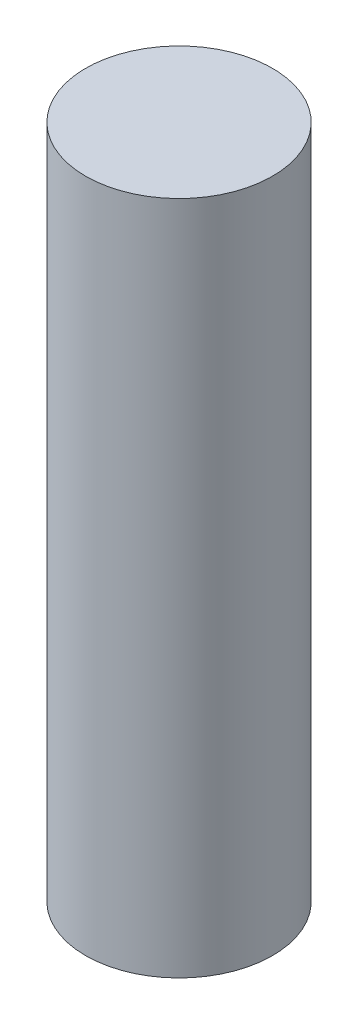
from build123d import *

# Parameters (mm, degrees)
ESQUISSE1_R        = 9
BOSS_EXTRU_1_DEPTH = 65


with BuildPart() as part:
    # Esquisse1 → Boss.-Extru.1 (new body)
    with BuildSketch(Plane(origin=(0, 0, 0), x_dir=(1, 0, 0), z_dir=(0, 1, 0))):
        Circle(ESQUISSE1_R)
    extrude(amount=BOSS_EXTRU_1_DEPTH)


solid = part.part
